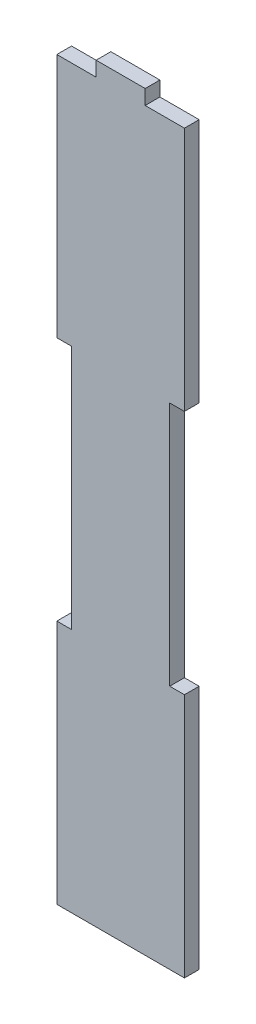
from build123d import *

# Parameters (mm, degrees)
BOSS_EXTRUDE1_DEPTH = 3


with BuildPart() as part:
    # Sketch1 → Boss-Extrude1 (new body)
    with BuildSketch(Plane.XY):
        Polygon((0, 100), (0, 150), (8, 150), (8, 153), (18, 153), (18, 150), (26, 150), (26, 100), (23, 100), (23, 50), (26, 50), (26, 0), (0, 0), (0, 50), (3, 50), (3, 100), align=None)
    extrude(amount=BOSS_EXTRUDE1_DEPTH)


solid = part.part
